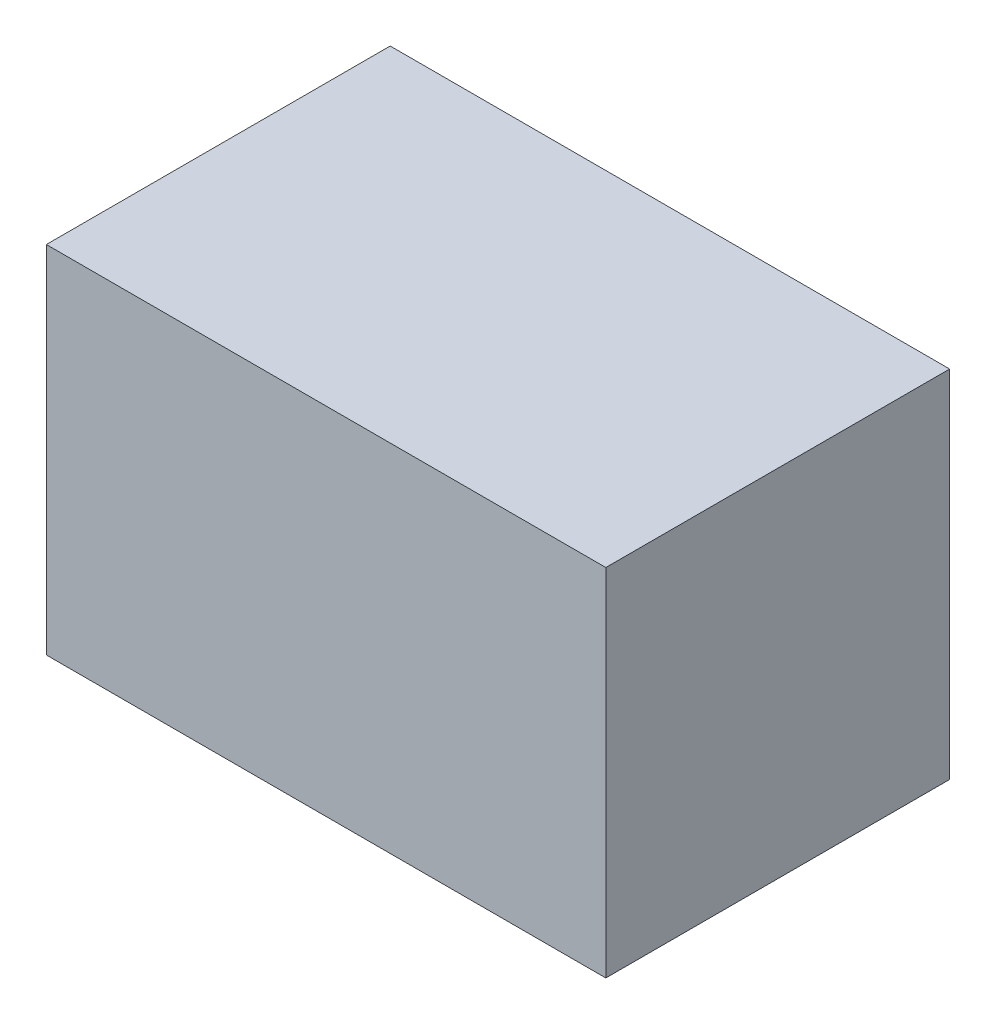
from build123d import *

# Parameters (mm, degrees)
SKETCH1_W           = 304.8
SKETCH1_H           = 187.325
BOSS_EXTRUDE1_DEPTH = 193.675


with BuildPart() as part:
    # Sketch1 → Boss-Extrude1 (new body)
    with BuildSketch(Plane(origin=(0, 0, 0), x_dir=(1, 0, 0), z_dir=(0, 1, 0))):
        with Locations((152.4, 93.6625)):
            Rectangle(SKETCH1_W, SKETCH1_H)
    extrude(amount=BOSS_EXTRUDE1_DEPTH)


solid = part.part
